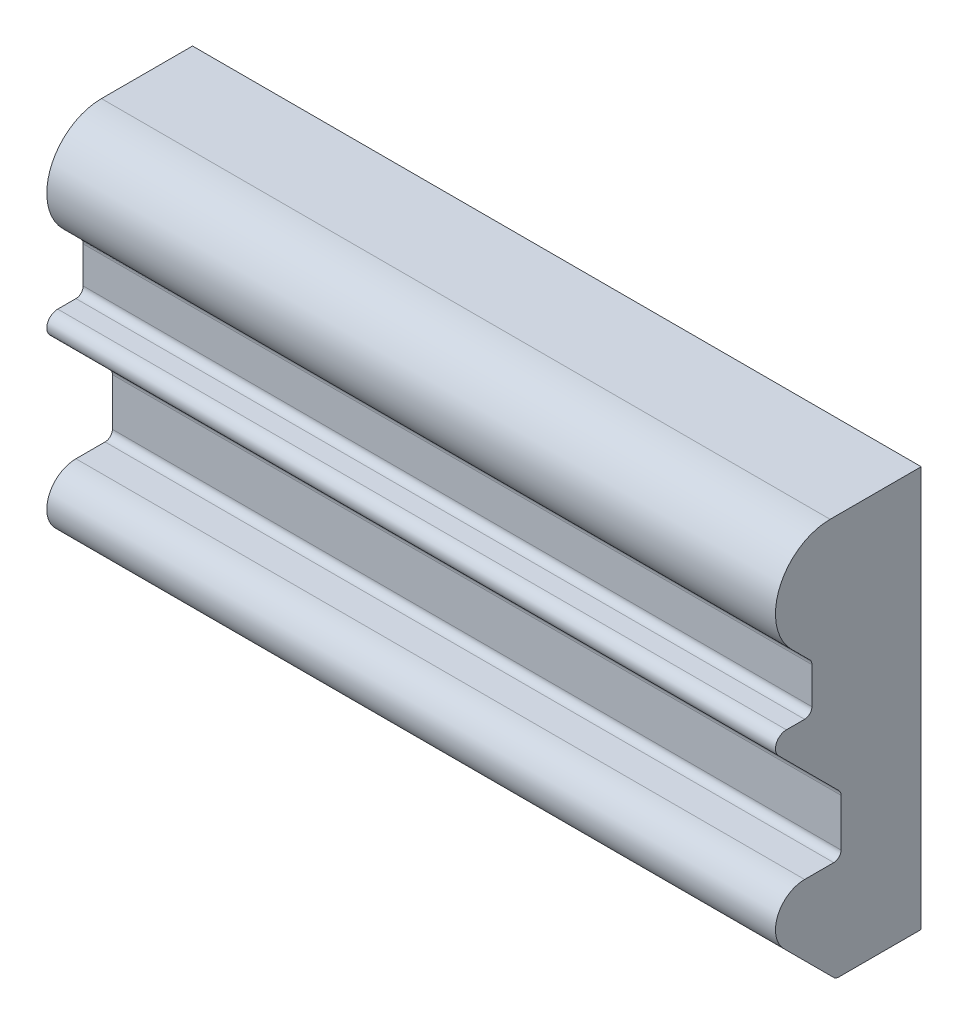
from build123d import *

# Parameters (mm, degrees)
SALIENTE_EXTRUIR1_DEPTH = 200


with BuildPart() as part:
    # Croquis1 → Saliente-Extruir1 (new body)
    with BuildSketch(Plane(origin=(0, 0, 0), x_dir=(0, 0, -1), z_dir=(1, 0, 0))):
        with BuildLine():
            Line((0, 0), (-22.597979746, 0))
            ThreePointArc((-22.597979746, 0), (-23.363346611, 0.152240935), (-24.012193309, 0.585786438))
            Line((-24.012193309, 0.585786438), (-37.656854249, 14.230447378))
            ThreePointArc((-37.656854249, 14.230447378), (-39.39103626, 22.948769087), (-32, 27.887301628))
            Line((-32, 27.887301628), (-24, 27.887301628))
            ThreePointArc((-24, 27.887301628), (-22.585786438, 28.473088065), (-22, 29.887301628))
            Line((-22, 29.887301628), (-22, 42.887301628))
            ThreePointArc((-22, 42.887301628), (-22.152240935, 43.652668493), (-22.585786438, 44.30151519))
            Line((-22.585786438, 44.30151519), (-39.121320344, 60.837049096))
            ThreePointArc((-39.121320344, 60.837049096), (-39.771638598, 64.106419737), (-37, 65.95836944))
            Line((-37, 65.95836944), (-32, 65.95836944))
            ThreePointArc((-32, 65.95836944), (-30.585786438, 66.544155877), (-30, 67.95836944))
            Line((-30, 67.95836944), (-30, 77.95836944))
            ThreePointArc((-30, 77.95836944), (-30.152240935, 78.723736304), (-30.585786438, 79.372583002))
            Line((-30.585786438, 79.372583002), (-35.606601718, 84.393398282))
            ThreePointArc((-35.606601718, 84.393398282), (-38.858192988, 100.740251485), (-25, 110))
            Line((-25, 110), (0, 110))
            Line((0, 110), (0, 0))
        make_face()
    extrude(amount=SALIENTE_EXTRUIR1_DEPTH)


solid = part.part
